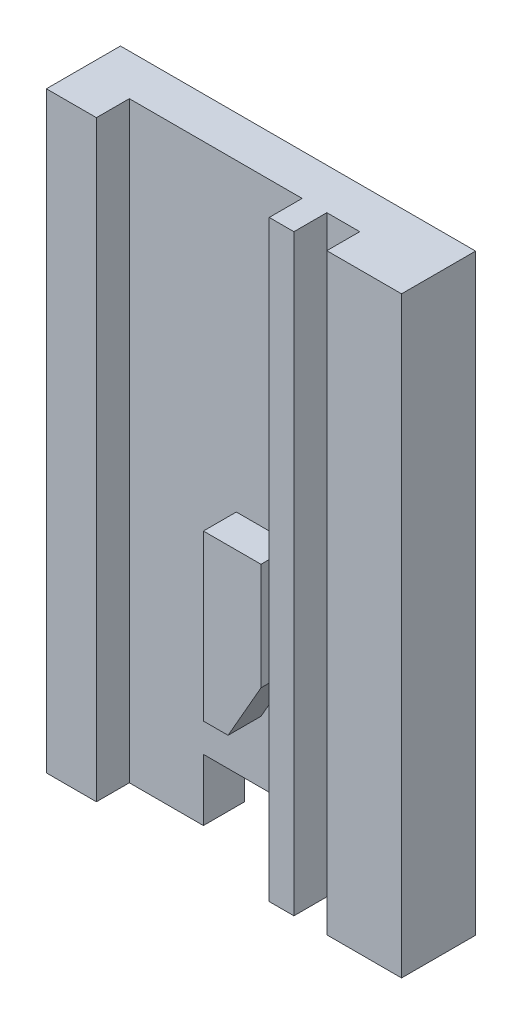
from build123d import *

# Parameters (mm, degrees)
SKETCH1_W           = 43.16
SKETCH1_H           = 72
BOSS_EXTRUDE1_DEPTH = 9
SKETCH2_W           = 37.08
SKETCH2_H           = 4
CUT_EXTRUDE1_DEPTH  = 73
SKETCH3_W           = 28.08
SKETCH3_H           = 7.5
CUT_EXTRUDE2_DEPTH  = 6
SKETCH4_W           = 16.08
SKETCH4_H           = 64.5
BOSS_EXTRUDE2_DEPTH = 4
SKETCH5_W           = 16.08
SKETCH5_H           = 9
BOSS_EXTRUDE3_DEPTH = 7.5
SKETCH6_W           = 4
SKETCH6_H           = 4
CUT_EXTRUDE3_DEPTH  = 73
BOSS_EXTRUDE4_DEPTH = 4
SCALE1_SCALE        = 0.25


with BuildPart() as part:
    # Sketch1 → Boss-Extrude1 (new body)
    with BuildSketch(Plane(origin=(0, 0, 0), x_dir=(-1, 0, 0), z_dir=(0, 0, -1))):
        Rectangle(SKETCH1_W, SKETCH1_H)
    extrude(amount=-BOSS_EXTRUDE1_DEPTH)

    # Sketch2 → Cut-Extrude1 (cut, through all)
    with BuildSketch(Plane(origin=(0, 36, 0), x_dir=(-1, 0, 0), z_dir=(0, 1, 0))):
        with Locations((-3.04, 7)):
            Rectangle(SKETCH2_W, SKETCH2_H)
    extrude(amount=-CUT_EXTRUDE1_DEPTH, mode=Mode.SUBTRACT)

    # Sketch3 → Cut-Extrude2 (cut, through all)
    with BuildSketch(Plane.XY.offset(5)):
        with Locations((7.54, -32.25)):
            Rectangle(SKETCH3_W, SKETCH3_H)
    extrude(amount=-CUT_EXTRUDE2_DEPTH, mode=Mode.SUBTRACT)

    # Sketch4 → Boss-Extrude2 (add)
    with BuildSketch(Plane.XY.offset(5)):
        with Locations((13.54, 3.75)):
            Rectangle(SKETCH4_W, SKETCH4_H)
    extrude(amount=BOSS_EXTRUDE2_DEPTH)

    # Sketch5 → Boss-Extrude3 (add)
    with BuildSketch(Plane.XZ.offset(28.5)):
        with Locations((13.54, 4.5)):
            Rectangle(SKETCH5_W, SKETCH5_H)
    extrude(amount=BOSS_EXTRUDE3_DEPTH)

    # Sketch6 → Cut-Extrude3 (cut, through all)
    with BuildSketch(Plane(origin=(0, 36, 0), x_dir=(-1, 0, 0), z_dir=(0, 1, 0))):
        with Locations((-10.5, 7)):
            Rectangle(SKETCH6_W, SKETCH6_H)
    extrude(amount=-CUT_EXTRUDE3_DEPTH, mode=Mode.SUBTRACT)

    # Sketch7 → Boss-Extrude4 (add)
    with BuildSketch(Plane.XY.offset(5)):
        Polygon((-2.5, -1), (4.5, -1), (4.5, -14), (0.5, -21), (-2.5, -21), align=None)
    extrude(amount=BOSS_EXTRUDE4_DEPTH)


with BuildPart() as part_1:
    # Scale1: scaled about (0.900583751, 0.451348466, 3.739254469)
    add(part.part.scale(SCALE1_SCALE).moved(Location((0.675437813, 0.33851135, 2.804440852))))


solid = part_1.part
